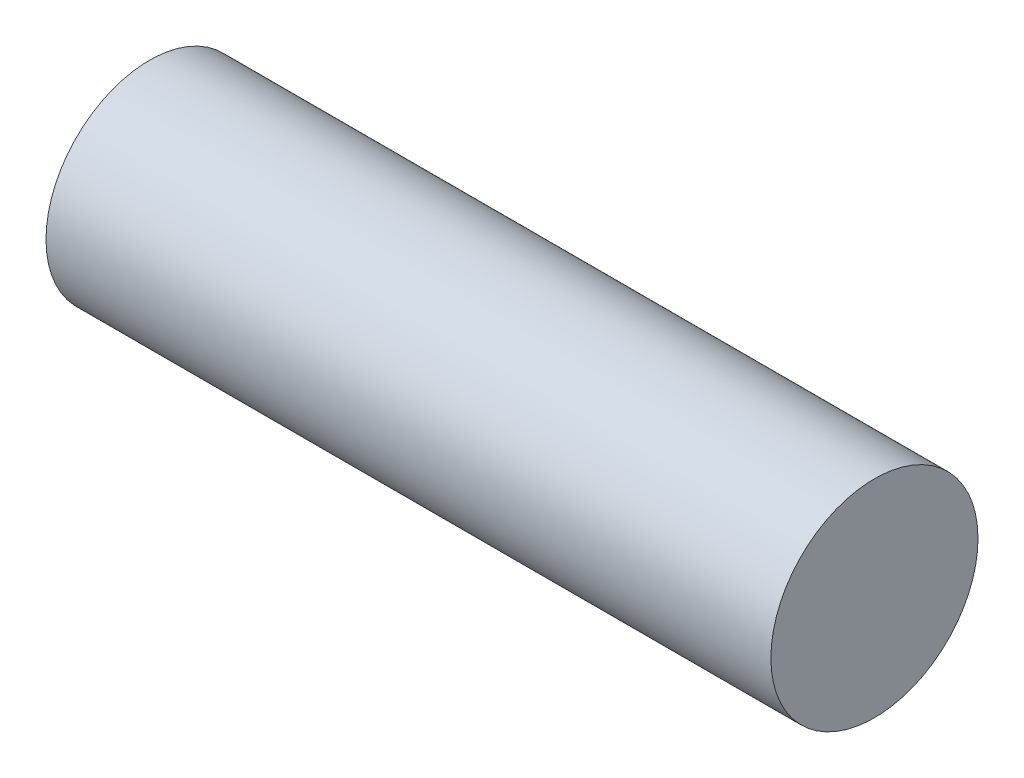
from build123d import *

# Parameters (mm, degrees)
SKETCH1_R           = 6.35
BOSS_EXTRUDE1_DEPTH = 22.225


with BuildPart() as part:
    # Sketch1 → Boss-Extrude1 (new body, symmetric)
    with BuildSketch(Plane(origin=(0, 0, 0), x_dir=(0, 0, -1), z_dir=(1, 0, 0))):
        Circle(SKETCH1_R)
    extrude(amount=BOSS_EXTRUDE1_DEPTH, both=True)


solid = part.part
